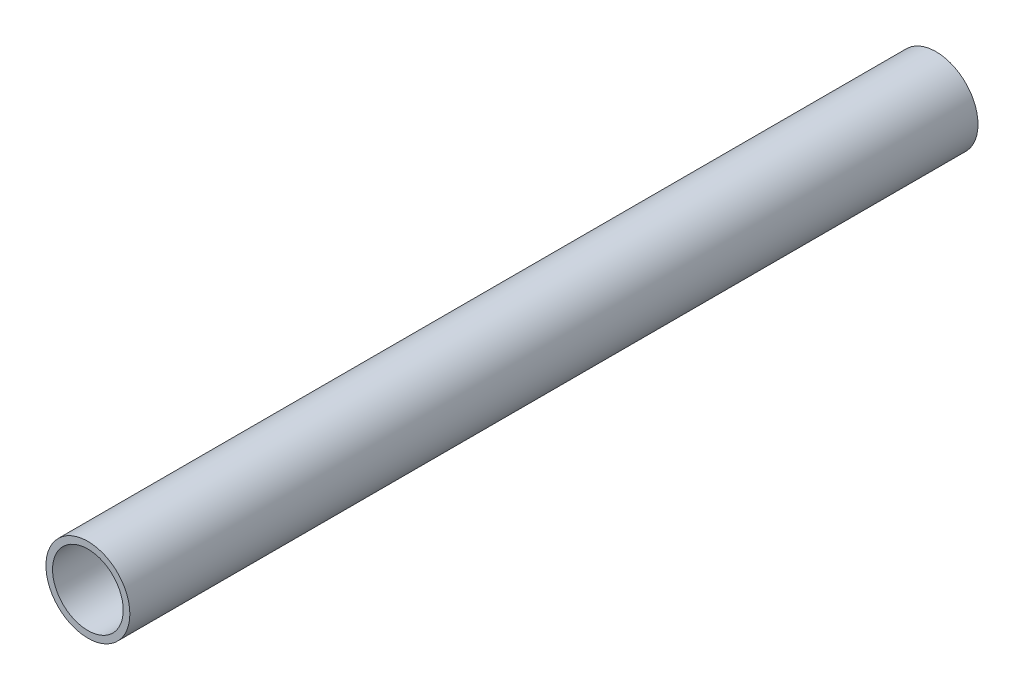
from build123d import *

# Parameters (mm, degrees)
SKETCH1_R           = 30.1625
SKETCH1_R_2         = 25.4
BOSS_EXTRUDE1_DEPTH = 304.8


with BuildPart() as part:
    # Sketch1 → Boss-Extrude1 (new body, symmetric)
    with BuildSketch(Plane.XY):
        Circle(SKETCH1_R)
        Circle(SKETCH1_R_2, mode=Mode.SUBTRACT)
    extrude(amount=BOSS_EXTRUDE1_DEPTH, both=True)


solid = part.part
